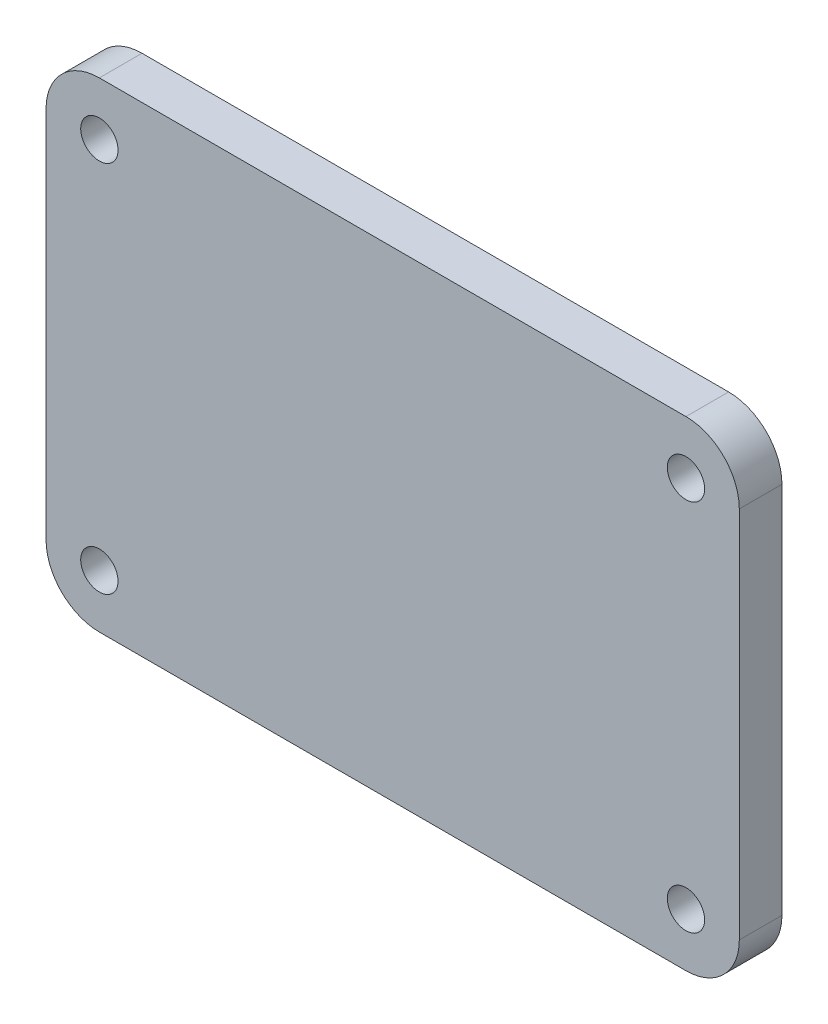
from build123d import *

# Parameters (mm, degrees)
SKETCH_1_W              = 65
SKETCH_1_H              = 45
EXTRUDE_1_DEPTH         = 4
HOLE_WIZARD_3_5_3_5_1_D = 3.5
FILLET_1_R              = 5


with BuildPart() as part:
    # 草图1 → 凸台-拉伸1 (new body)
    with BuildSketch(Plane.XY):
        Rectangle(SKETCH_1_W, SKETCH_1_H)
    extrude(amount=EXTRUDE_1_DEPTH)

    # Ø3.5 (3.5) 直径孔1 (through all)
    with Locations(Plane.XY.offset(4)):
        with Locations((-27.5, 17.5), (-27.5, -17.5), (27.5, 17.5), (27.5, -17.5)):
            Hole(HOLE_WIZARD_3_5_3_5_1_D / 2)

    # 圆角1
    fillet_1_edges = [part.edges().sort_by_distance(p)[0] for p in [
        (32.5, -22.5, 2),
        (-32.5, -22.5, 2),
        (-32.5, 22.5, 2),
        (32.5, 22.5, 2),
    ]]
    fillet(fillet_1_edges, radius=FILLET_1_R)


solid = part.part
